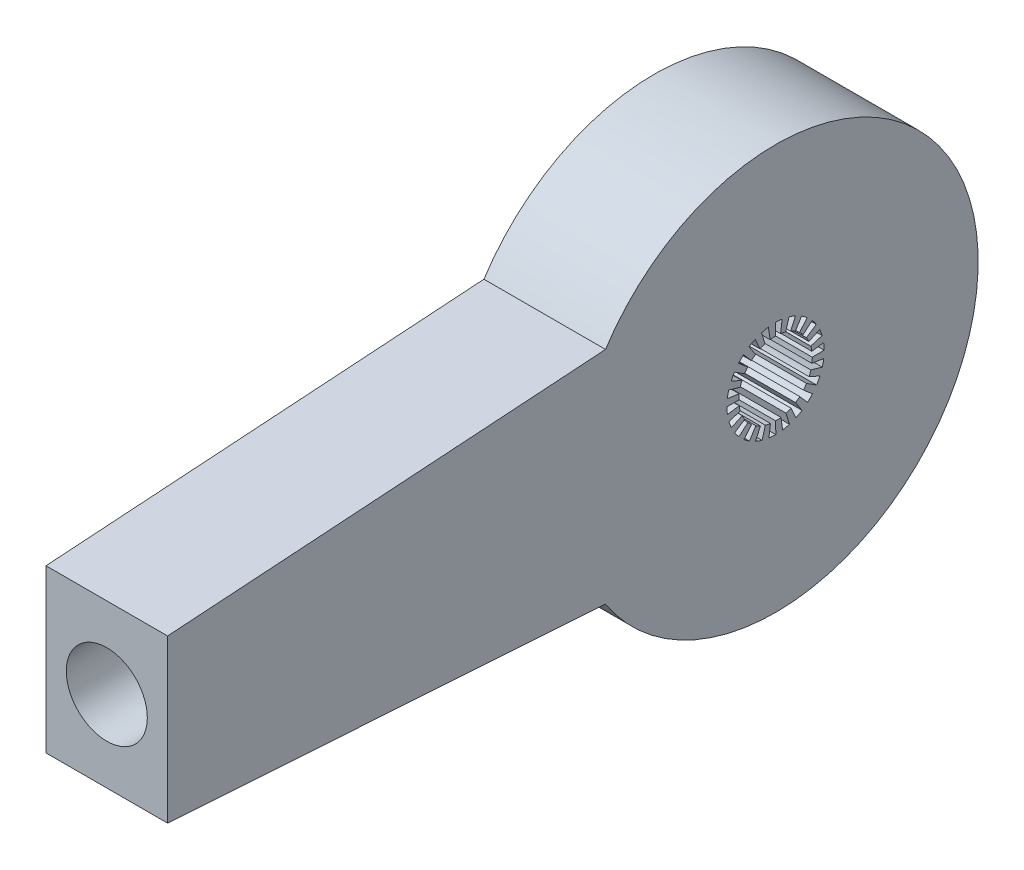
from build123d import *

# Parameters (mm, degrees)
SKETCH1_R           = 6
BOSS_EXTRUDE1_DEPTH = 15
SKETCH2_R           = 5
CUT_EXTRUDE1_DEPTH  = 30
BOSS_EXTRUDE2_DEPTH = 15


with BuildPart() as part:
    # Sketch1 → Boss-Extrude1 (new body)
    with BuildSketch(Plane(origin=(0, 0, 0), x_dir=(0, 0, -1), z_dir=(1, 0, 0))):
        with BuildLine():
            ThreePointArc((25, 0), (7.092163634, 23.972926709), (-20.976097199, 13.60159352))
            ThreePointArc((-20.976097199, 13.60159352), (-25, 0), (-20.976097199, -13.60159352))
            ThreePointArc((-20.976097199, -13.60159352), (7.092163634, -23.972926709), (25, 0))
        make_face()
        Circle(SKETCH1_R, mode=Mode.SUBTRACT)
        with BuildLine():
            ThreePointArc((-20.976097199, -13.60159352), (-25, 0), (-20.976097199, 13.60159352))
            Line((-20.976097199, 13.60159352), (-75, 10))
            Line((-75, 10), (-75, -10))
            Line((-75, -10), (-20.976097199, -13.60159352))
        make_face()
    extrude(amount=BOSS_EXTRUDE1_DEPTH)

    # Sketch2 → Cut-Extrude1 (cut)
    with BuildSketch(Plane.XY.offset(75)):
        with Locations((7.5, 0)):
            Circle(SKETCH2_R)
    extrude(amount=-CUT_EXTRUDE1_DEPTH, mode=Mode.SUBTRACT)

    # Sketch4 → Boss-Extrude2 (add)
    with BuildSketch(Plane(origin=(15, 0, 0), x_dir=(0, 0, -1), z_dir=(1, 0, 0))):
        with BuildLine():
            Line((0.623259764, 4.490102446), (0.824935512, 5.943019552))
            ThreePointArc((0.824935512, 5.943019552), (1.24671071, 5.869046976), (1.662135778, 5.765180366))
            Line((1.662135778, 5.765180366), (1.25578586, 4.355740418))
            ThreePointArc((1.25578586, 4.355740418), (0.941921654, 4.434214283), (0.623259764, 4.490102446))
        make_face()
        with BuildLine():
            Line((1.863021407, 4.132629181), (2.465861922, 5.469874312))
            ThreePointArc((2.465861922, 5.469874312), (2.849711777, 5.280070339), (3.219046605, 5.063372291))
            Line((3.219046605, 5.063372291), (2.432071594, 3.825506564))
            ThreePointArc((2.432071594, 3.825506564), (2.153029737, 3.989227452), (1.863021407, 4.132629181))
        make_face()
        with BuildLine():
            Line((2.951852135, 3.440354878), (3.907018863, 4.553592384))
            ThreePointArc((3.907018863, 4.553592384), (4.221846144, 4.263333806), (4.515169421, 3.951359905))
            Line((4.515169421, 3.951359905), (3.411325351, 2.98535292))
            ThreePointArc((3.411325351, 2.98535292), (3.189712154, 3.221057138), (2.951852135, 3.440354878))
        make_face()
        with BuildLine():
            Line((3.801541359, 2.469363482), (5.031652372, 3.268405484))
            ThreePointArc((5.031652372, 3.268405484), (5.251951644, 2.901207322), (5.445500063, 2.51923184))
            Line((5.445500063, 2.51923184), (4.114213817, 1.903343737))
            ThreePointArc((4.114213817, 1.903343737), (3.967983063, 2.191935931), (3.801541359, 2.469363482))
        make_face()
        with BuildLine():
            Line((4.34325231, 1.298318944), (5.74865133, 1.718431809))
            ThreePointArc((5.74865133, 1.718431809), (5.856575257, 1.304042275), (5.934668676, 0.883010593))
            Line((5.934668676, 0.883010593), (4.483793147, 0.667136964))
            ThreePointArc((4.483793147, 0.667136964), (4.424791583, 0.98523711), (4.34325231, 1.298318944))
        make_face()
        with BuildLine():
            Line((4.53309879, 0.022092326), (5.999928747, 0.029241008))
            ThreePointArc((5.999928747, 0.029241008), (5.986733973, -0.398768521), (5.943045727, -0.82474692))
            Line((5.943045727, -0.82474692), (4.490122222, -0.623117278))
            ThreePointArc((4.490122222, -0.623117278), (4.523129803, -0.301279761), (4.53309879, 0.022092326))
        make_face()
        with BuildLine():
            Line((4.355700565, -1.255924081), (5.765127618, -1.662318725))
            ThreePointArc((5.765127618, -1.662318725), (5.631883107, -2.069273464), (5.469952559, -2.465688343))
            Line((5.469952559, -2.465688343), (4.132688299, -1.862890264))
            ThreePointArc((4.132688299, -1.862890264), (4.255030947, -1.563388739), (4.355700565, -1.255924081))
        make_face()
        with BuildLine():
            Line((3.825429385, -2.432192989), (5.063270137, -3.219207281))
            ThreePointArc((5.063270137, -3.219207281), (4.820770566, -3.572138177), (4.553716365, -3.906874361))
            Line((4.553716365, -3.906874361), (3.440448548, -2.95174296))
            ThreePointArc((3.440448548, -2.95174296), (3.64221479, -2.698841258), (3.825429385, -2.432192989))
        make_face()
        with BuildLine():
            Line((2.985244666, -3.411420085), (3.951216622, -4.515294808))
            ThreePointArc((3.951216622, -4.515294808), (3.619107863, -4.785609499), (3.268565153, -5.031548652))
            Line((3.268565153, -5.031548652), (2.469484116, -3.801462996))
            ThreePointArc((2.469484116, -3.801462996), (2.734328051, -3.615649709), (2.985244666, -3.411420085))
        make_face()
        with BuildLine():
            Line((1.903213179, -4.114274214), (2.519059035, -5.445580004))
            ThreePointArc((2.519059035, -5.445580004), (2.124246566, -5.6113792), (1.718614231, -5.748596796))
            Line((1.718614231, -5.748596796), (1.298456769, -4.343211108))
            ThreePointArc((1.298456769, -4.343211108), (1.604922315, -4.239539724), (1.903213179, -4.114274214))
        make_face()
        with BuildLine():
            Line((0.666994679, -4.483814315), (0.882822266, -5.934696694))
            ThreePointArc((0.882822266, -5.934696694), (0.457291444, -5.982548331), (0.029431406, -5.999927816))
            Line((0.029431406, -5.999927816), (0.022236176, -4.533098087))
            ThreePointArc((0.022236176, -4.533098087), (0.345495319, -4.519967444), (0.666994679, -4.483814315))
        make_face()
        with BuildLine():
            Line((-0.623259764, -4.490102446), (-0.824935512, -5.943019552))
            ThreePointArc((-0.824935512, -5.943019552), (-1.24671071, -5.869046976), (-1.662135778, -5.765180366))
            Line((-1.662135778, -5.765180366), (-1.25578586, -4.355740418))
            ThreePointArc((-1.25578586, -4.355740418), (-0.941921654, -4.434214283), (-0.623259764, -4.490102446))
        make_face()
        with BuildLine():
            Line((-1.863021407, -4.132629181), (-2.465861922, -5.469874312))
            ThreePointArc((-2.465861922, -5.469874312), (-2.849711777, -5.280070339), (-3.219046605, -5.063372291))
            Line((-3.219046605, -5.063372291), (-2.432071594, -3.825506564))
            ThreePointArc((-2.432071594, -3.825506564), (-2.153029737, -3.989227452), (-1.863021407, -4.132629181))
        make_face()
        with BuildLine():
            Line((-2.951852135, -3.440354878), (-3.907018863, -4.553592384))
            ThreePointArc((-3.907018863, -4.553592384), (-4.221846144, -4.263333806), (-4.515169421, -3.951359905))
            Line((-4.515169421, -3.951359905), (-3.411325351, -2.98535292))
            ThreePointArc((-3.411325351, -2.98535292), (-3.189712154, -3.221057138), (-2.951852135, -3.440354878))
        make_face()
        with BuildLine():
            Line((-3.801541359, -2.469363482), (-5.031652372, -3.268405484))
            ThreePointArc((-5.031652372, -3.268405484), (-5.251951644, -2.901207322), (-5.445500063, -2.51923184))
            Line((-5.445500063, -2.51923184), (-4.114213817, -1.903343737))
            ThreePointArc((-4.114213817, -1.903343737), (-3.967983063, -2.191935931), (-3.801541359, -2.469363482))
        make_face()
        with BuildLine():
            Line((-4.34325231, -1.298318944), (-5.74865133, -1.718431809))
            ThreePointArc((-5.74865133, -1.718431809), (-5.856575257, -1.304042275), (-5.934668676, -0.883010593))
            Line((-5.934668676, -0.883010593), (-4.483793147, -0.667136964))
            ThreePointArc((-4.483793147, -0.667136964), (-4.424791583, -0.98523711), (-4.34325231, -1.298318944))
        make_face()
        with BuildLine():
            Line((-4.53309879, -0.022092326), (-5.999928747, -0.029241008))
            ThreePointArc((-5.999928747, -0.029241008), (-5.986733973, 0.398768521), (-5.943045727, 0.82474692))
            Line((-5.943045727, 0.82474692), (-4.490122222, 0.623117278))
            ThreePointArc((-4.490122222, 0.623117278), (-4.523129803, 0.301279761), (-4.53309879, -0.022092326))
        make_face()
        with BuildLine():
            Line((-4.355700565, 1.255924081), (-5.765127618, 1.662318725))
            ThreePointArc((-5.765127618, 1.662318725), (-5.631883107, 2.069273464), (-5.469952559, 2.465688343))
            Line((-5.469952559, 2.465688343), (-4.132688299, 1.862890264))
            ThreePointArc((-4.132688299, 1.862890264), (-4.255030947, 1.563388739), (-4.355700565, 1.255924081))
        make_face()
        with BuildLine():
            Line((-3.825429385, 2.432192989), (-5.063270137, 3.219207281))
            ThreePointArc((-5.063270137, 3.219207281), (-4.820770566, 3.572138177), (-4.553716365, 3.906874361))
            Line((-4.553716365, 3.906874361), (-3.440448548, 2.95174296))
            ThreePointArc((-3.440448548, 2.95174296), (-3.64221479, 2.698841258), (-3.825429385, 2.432192989))
        make_face()
        with BuildLine():
            Line((-2.985244666, 3.411420085), (-3.951216622, 4.515294808))
            ThreePointArc((-3.951216622, 4.515294808), (-3.619107863, 4.785609499), (-3.268565153, 5.031548652))
            Line((-3.268565153, 5.031548652), (-2.469484116, 3.801462996))
            ThreePointArc((-2.469484116, 3.801462996), (-2.734328051, 3.615649709), (-2.985244666, 3.411420085))
        make_face()
        with BuildLine():
            Line((-1.903213179, 4.114274214), (-2.519059035, 5.445580004))
            ThreePointArc((-2.519059035, 5.445580004), (-2.124246566, 5.6113792), (-1.718614231, 5.748596796))
            Line((-1.718614231, 5.748596796), (-1.298456769, 4.343211108))
            ThreePointArc((-1.298456769, 4.343211108), (-1.604922315, 4.239539724), (-1.903213179, 4.114274214))
        make_face()
        with BuildLine():
            Line((-0.666994679, 4.483814315), (-0.882822266, 5.934696694))
            ThreePointArc((-0.882822266, 5.934696694), (-0.457291444, 5.982548331), (-0.029431406, 5.999927816))
            Line((-0.029431406, 5.999927816), (-0.022236176, 4.533098087))
            ThreePointArc((-0.022236176, 4.533098087), (-0.345495319, 4.519967444), (-0.666994679, 4.483814315))
        make_face()
    extrude(amount=-BOSS_EXTRUDE2_DEPTH)


solid = part.part
